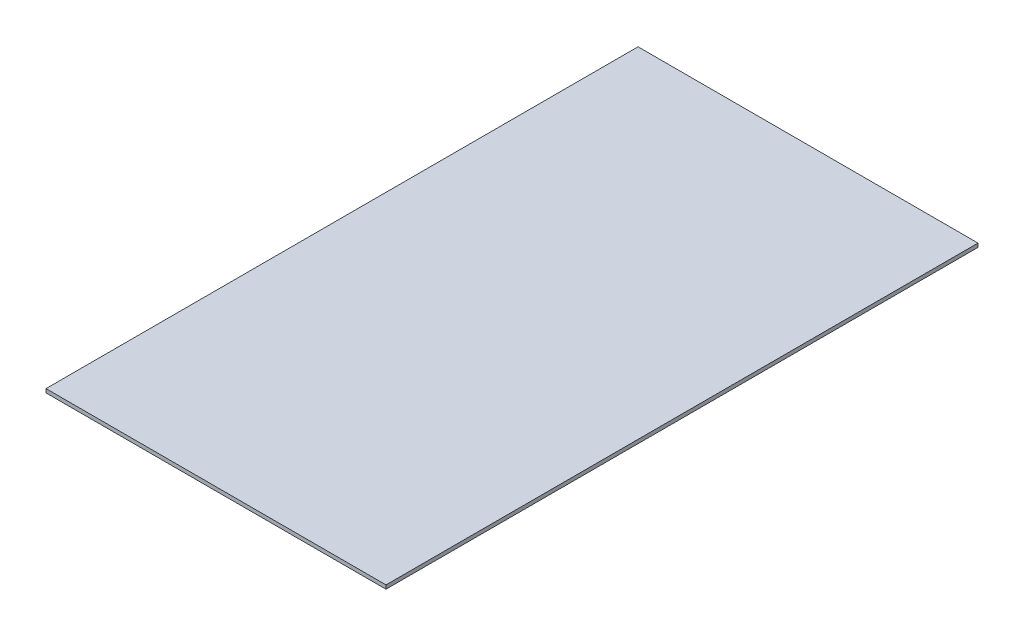
from build123d import *

# Parameters (mm, degrees)
SKETCH1_W           = 290
SKETCH1_H           = 505
BOSS_EXTRUDE1_DEPTH = 3.2


with BuildPart() as part:
    # Sketch1 → Boss-Extrude1 (new body)
    with BuildSketch(Plane(origin=(0, 0, 0), x_dir=(1, 0, 0), z_dir=(0, 1, 0))):
        Rectangle(SKETCH1_W, SKETCH1_H)
    extrude(amount=BOSS_EXTRUDE1_DEPTH)


solid = part.part
